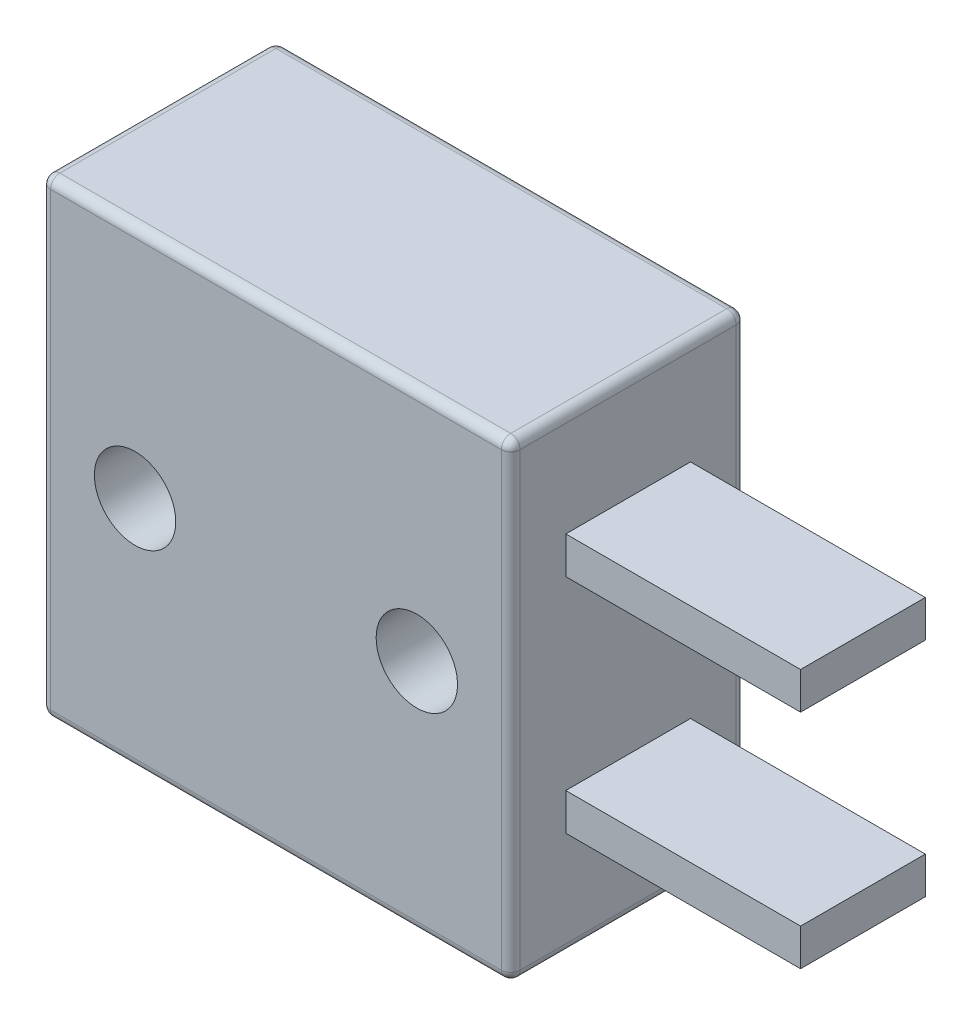
from build123d import *

# Parameters (mm, degrees)
SKETCH1_W           = 12.7
SKETCH1_H           = 12.7
SKETCH1_R           = 1.1
BOSS_EXTRUDE1_DEPTH = 6.35
SKETCH2_W           = 6.35
SKETCH2_H           = 1
BOSS_EXTRUDE2_DEPTH = 1.68671875
FILLET1_R           = 0.254


with BuildPart() as part:
    # Sketch1 → Boss-Extrude1 (new body)
    with BuildSketch(Plane.XY):
        Rectangle(SKETCH1_W, SKETCH1_H)
        with Locations((-3.81, 0)):
            Circle(SKETCH1_R, mode=Mode.SUBTRACT)
        with Locations((3.81, 0)):
            Circle(SKETCH1_R, mode=Mode.SUBTRACT)
    extrude(amount=BOSS_EXTRUDE1_DEPTH)

    # Sketch2 → Boss-Extrude2 (add, symmetric)
    with BuildSketch(Plane.XY.offset(3.175)):
        with Locations((9.525, 3.0048)):
            Rectangle(SKETCH2_W, SKETCH2_H)
        with Locations((9.525, -3.0048)):
            Rectangle(SKETCH2_W, SKETCH2_H)
    extrude(amount=BOSS_EXTRUDE2_DEPTH, both=True)

    # Fillet1
    fillet1_edges = [part.edges().sort_by_distance(p)[0] for p in [
        (-6.35, 0, 6.35),
        (0, -6.35, 6.35),
        (6.35, 0, 6.35),
        (0, -6.35, 0),
        (-6.35, 0, 0),
        (0, 6.35, 0),
        (6.35, 0, 0),
        (6.35, -6.35, 3.175),
        (-6.35, -6.35, 3.175),
        (-6.35, 6.35, 3.175),
        (6.35, 6.35, 3.175),
        (0, 6.35, 6.35),
    ]]
    fillet(fillet1_edges, radius=FILLET1_R)


solid = part.part
